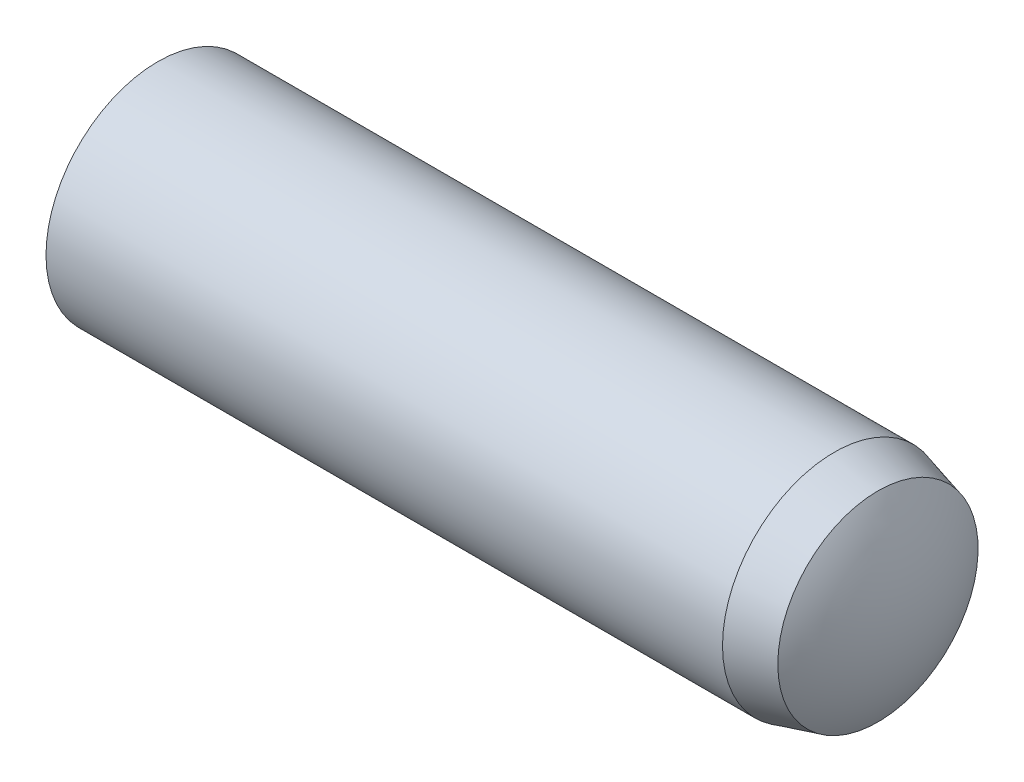
from build123d import *

# Parameters (mm, degrees)
SKETCH2_R           = 4
EXTRUDE1_DEPTH      = 14
EXTRUDE1_DEPTH_BACK = 14


with BuildPart() as part:
    # Sketch2 → Extrude1 (new body, two sides)
    with BuildSketch(Plane(origin=(0, 0, 0), x_dir=(0, 0, -1), z_dir=(1, 0, 0))) as extrude1_sk:
        Circle(SKETCH2_R)
    extrude(amount=EXTRUDE1_DEPTH)
    extrude(extrude1_sk.sketch, amount=-EXTRUDE1_DEPTH_BACK)

    # Sketch5 → Cut-Revolve1 (revolve, cut)
    with BuildSketch(Plane.XY):
        with BuildLine():
            Line((11.4, 4), (11.4, 4.5))
            Line((11.4, 4.5), (14.5, 4.5))
            Line((14.5, 4.5), (14.5, 0))
            Line((14.5, 0), (14, 0))
            ThreePointArc((14, 0), (13.734740106, 1.864961038), (12.96, 3.58199926))
            Line((12.96, 3.58199926), (11.4, 4))
        make_face()
        with BuildLine():
            Line((-12.8, 4), (-12.8, 4.5))
            Line((-12.8, 4.5), (-14.5, 4.5))
            Line((-14.5, 4.5), (-14.5, 0))
            Line((-14.5, 0), (-14, 0))
            ThreePointArc((-14, 0), (-13.693537673, 2.088061302), (-12.8, 4))
        make_face()
    revolve(axis=Axis((-14, 0, 0), (1, 0, 0)), mode=Mode.SUBTRACT)


solid = part.part
